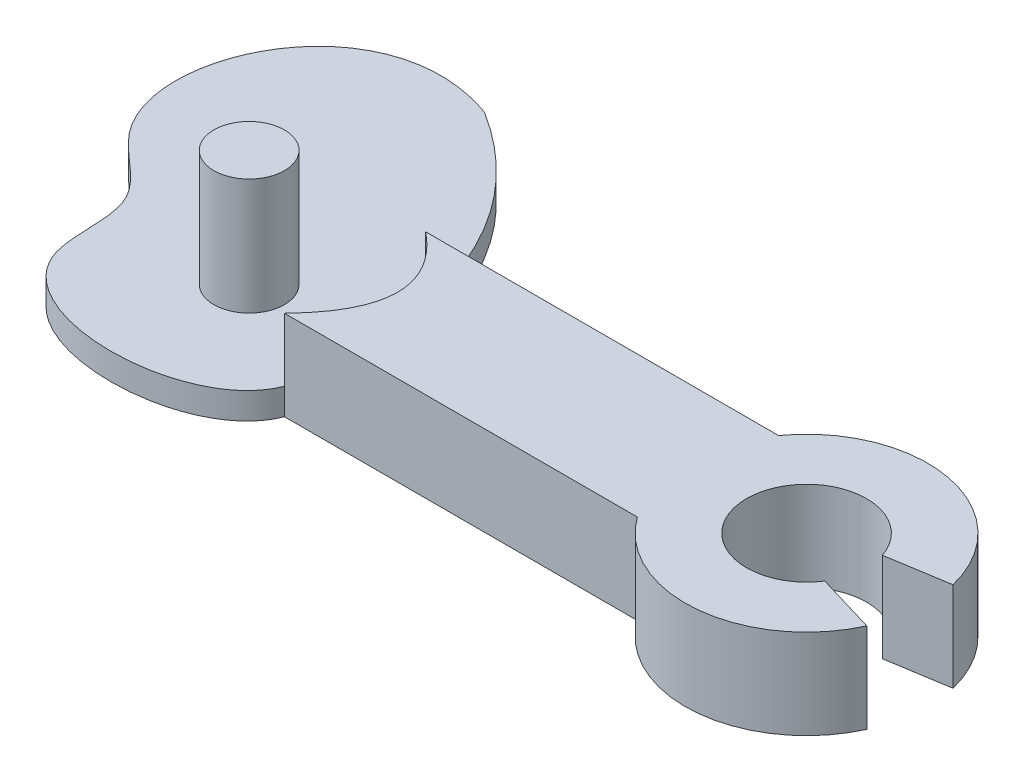
from build123d import *

# Parameters (mm, degrees)
SKETCH1_W               = 10
SKETCH1_H               = 4
BOSS_EXTRUDE2_DEPTH     = 2.54
SKETCH3_R               = 1
BOSS_EXTRUDE3_DEPTH     = 1.5
SKETCH4_R               = 1
BOSS_EXTRUDE5_DEPTH     = 1.5
SKETCH6_R               = 1
CUT_EXTRUDE1_DEPTH      = 2.54
CUT_EXTRUDE1_DEPTH_BACK = 1.27


with BuildPart() as part:
    # Sketch1 → Boss-Extrude2 (new body)
    with BuildSketch(Plane(origin=(0, 0, 0), x_dir=(1, 0, 0), z_dir=(0, 1, 0))):
        with BuildLine():
            add(Edge.make_bspline(
                [(-3.892071286, 7.55845385), (-0.771451313, 5.601679727), (0, 2)],
                knots=[0, 0, 0, 1, 1, 1], degree=2))
            Line((0, 2), (0, -2))
            add(Edge.make_bspline(
                [(0, -2), (-0.807019421, -4.0986057), (-7.360800537, -4.196276699), (-6.343457725, 0.548340217), (-10.778232398, 2.929025773), (-8.051665625, 9.045483404), (-3.892071286, 7.55845385)],
                knots=[0, 0, 0, 0, 0.355860313, 0.470047608, 0.583542681, 1, 1, 1, 1], degree=3))
        make_face()
        with Locations((5, 0)):
            Rectangle(SKETCH1_W, SKETCH1_H)
        with BuildLine():
            Line((11.094, 0), (10, 0))
            Line((10, 0), (10, -2))
            ThreePointArc((10, -2), (13.128207579, -3.419757491), (15.922350304, -1.421217919))
            Line((15.922350304, -1.421217919), (14.22610231, -0.916014724))
            ThreePointArc((14.22610231, -0.916014724), (12.316807128, -1.631651606), (11.094, 0))
        make_face()
        with BuildLine():
            Line((10, 2), (10, 0))
            Line((10, 0), (11.094, 0))
            ThreePointArc((11.094, 0), (12.524636877, 1.678524205), (14.408639421, 0.531920615))
            Line((14.408639421, 0.531920615), (16.133188964, 0.810094479))
            ThreePointArc((16.133188964, 0.810094479), (13.448428406, 3.373152748), (10, 2))
        make_face()
    extrude(amount=BOSS_EXTRUDE2_DEPTH)

    # Sketch3 → Boss-Extrude3 (add)
    with BuildSketch(Plane(origin=(0, 2.54, 0), x_dir=(1, 0, 0), z_dir=(0, 1, 0))):
        with Locations((-3, 0)):
            Circle(SKETCH3_R)
    extrude(amount=BOSS_EXTRUDE3_DEPTH)

    # Sketch4 → Boss-Extrude5 (add)
    with BuildSketch(Plane(origin=(0, 0, 0), x_dir=(-1, 0, 0), z_dir=(0, -1, 0))):
        with Locations((4.872437244, 3.501336217)):
            Circle(SKETCH4_R)
    extrude(amount=BOSS_EXTRUDE5_DEPTH)

    # Sketch6 → Cut-Extrude1 (cut, two sides)
    with BuildSketch(Plane(origin=(0, 2.02, 0), x_dir=(1, 0, 0), z_dir=(0, 1, 0))) as cut_extrude1_sk:
        with BuildLine():
            Line((0, 8.859088838), (0, 2))
            add(Edge.make_bspline(
                [(0, 2), (2.175152806, 0.238184258), (0, -2)],
                knots=[0, 0, 0, 1, 1, 1], degree=2))
            Line((0, -2), (0, -4.672458071))
            Line((0, -4.672458071), (-11.092635024, -4.672458071))
            Line((-11.092635024, -4.672458071), (-11.092635024, 8.859088838))
            Line((-11.092635024, 8.859088838), (0, 8.859088838))
        make_face()
        with Locations((-3, 0)):
            Circle(SKETCH6_R, mode=Mode.SUBTRACT)
    extrude(amount=CUT_EXTRUDE1_DEPTH, mode=Mode.SUBTRACT)
    extrude(cut_extrude1_sk.sketch, amount=-CUT_EXTRUDE1_DEPTH_BACK, mode=Mode.SUBTRACT)


solid = part.part
